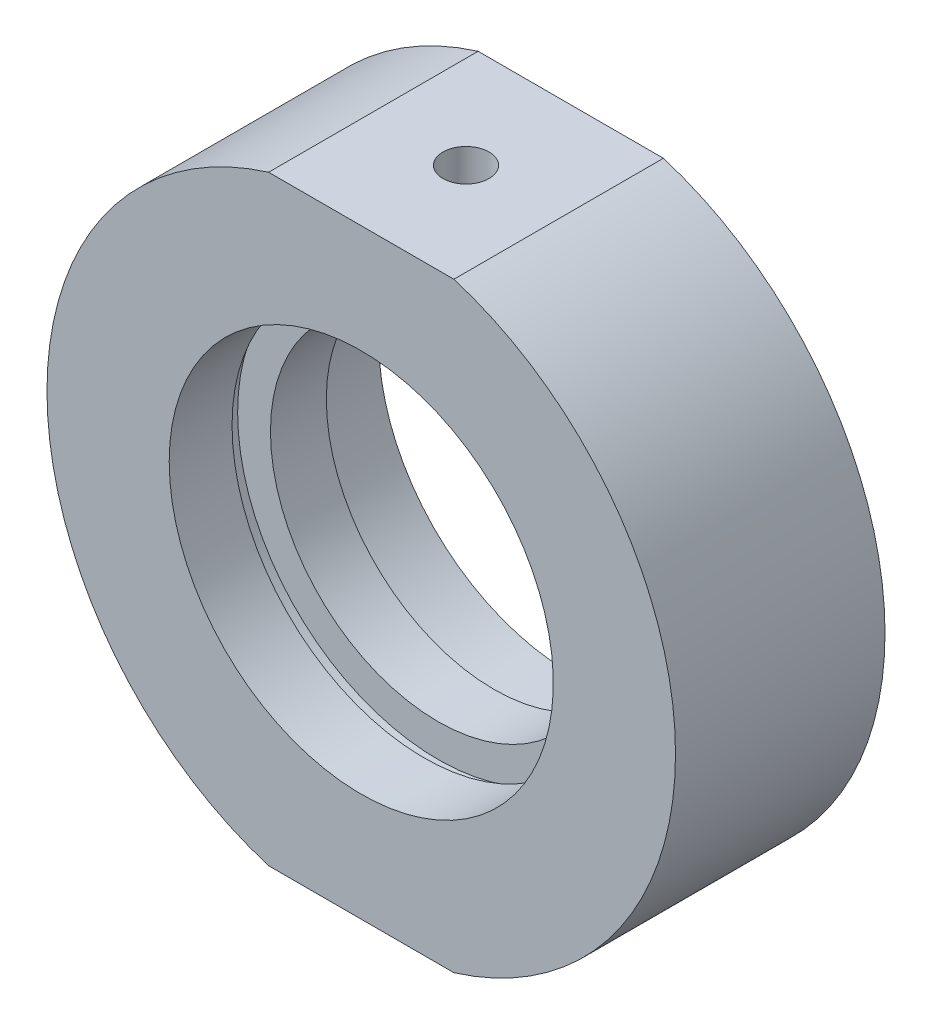
from build123d import *

# Parameters (mm, degrees)
SKETCH_2_W             = 64.02174429
SKETCH_2_H             = 9.248919907
CUT_EXTRUDE_1_DEPTH    = 49
HOLE_WIZARD_M4_2_D     = 3.3
HOLE_WIZARD_M4_2_DEPTH = 5.5
HOLE_WIZARD_M4_2_TIP   = 0.991420021
HOLE_WIZARD_M6_2_D     = 5
HOLE_WIZARD_M6_2_DEPTH = 5.5
HOLE_WIZARD_M6_2_TIP   = 1.502151548


with BuildPart() as part:
    # 草图1 → 旋转1 (revolve)
    with BuildSketch(Plane(origin=(0, 0, 0), x_dir=(1, 0, 0), z_dir=(0, 1, 0)), mode=Mode.PRIVATE) as revolve_1_sk:
        Polygon((22.5, 7.5), (22.5, -7.5), (13.75, -7.5), (13.75, -3), (14.35, -3), (14.35, -2), (12, -2), (12, 2), (14.35, 2), (14.35, 3), (13.75, 3), (13.75, 7.5), align=None)
    revolve(revolve_1_sk.sketch.rotate(Axis((0, 0, -31.9390681), (0, 0, 1)), 180), axis=Axis((0, 0, -31.9390681), (0, 0, 1)))  # turned: the seam where the file's is

    # 草图2 → 切除-拉伸1 (cut)
    with BuildSketch(Plane.XY.offset(7.5)):
        with Locations((-1.141100508, 26.124459954)):
            Rectangle(SKETCH_2_W, SKETCH_2_H)
        with Locations((-1.141100508, -26.124459954)):
            Rectangle(SKETCH_2_W, SKETCH_2_H)
    extrude(amount=-CUT_EXTRUDE_1_DEPTH, mode=Mode.SUBTRACT)

    # M4 螺纹孔2
    with Locations(Plane(origin=(0, 21.5, 0), x_dir=(1, 0, 0), z_dir=(0, 1, 0))):
        with Locations((0, 0)):
            Hole(HOLE_WIZARD_M4_2_D / 2, depth=HOLE_WIZARD_M4_2_DEPTH)
            with Locations((0, 0, -(HOLE_WIZARD_M4_2_DEPTH + HOLE_WIZARD_M4_2_TIP / 2))):  # 118° drill point
                Cone(0, HOLE_WIZARD_M4_2_D / 2, HOLE_WIZARD_M4_2_TIP, mode=Mode.SUBTRACT)

    # M6 螺纹孔2
    with Locations(Plane(origin=(0, -21.5, 0), x_dir=(-1, 0, 0), z_dir=(0, -1, 0))):
        with Locations((0, 0)):
            Hole(HOLE_WIZARD_M6_2_D / 2, depth=HOLE_WIZARD_M6_2_DEPTH)
            with Locations((0, 0, -(HOLE_WIZARD_M6_2_DEPTH + HOLE_WIZARD_M6_2_TIP / 2))):  # 118° drill point
                Cone(0, HOLE_WIZARD_M6_2_D / 2, HOLE_WIZARD_M6_2_TIP, mode=Mode.SUBTRACT)


solid = part.part
